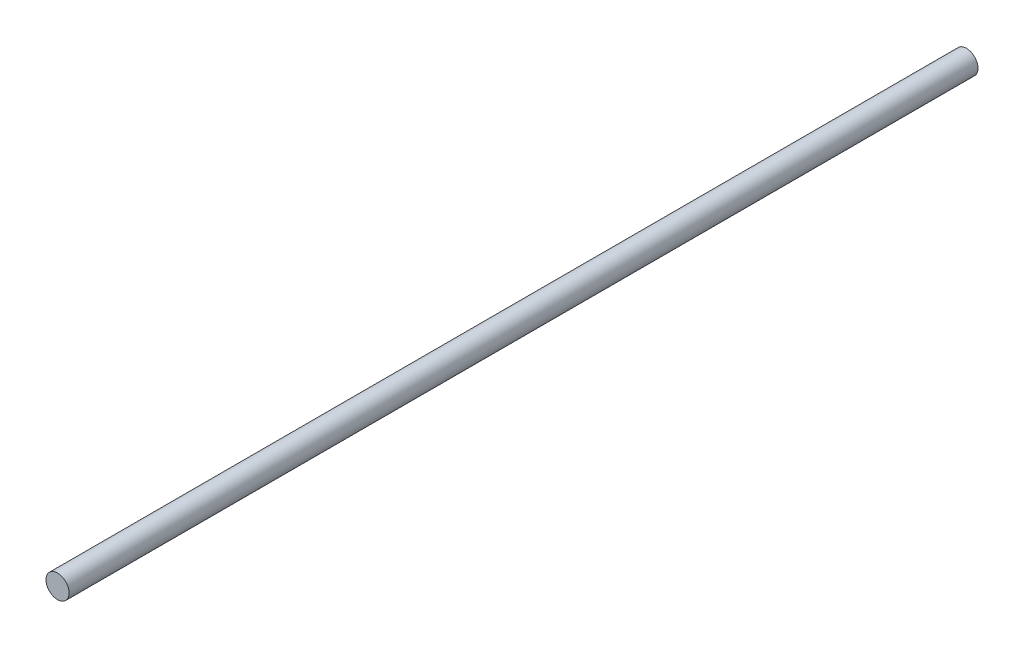
from build123d import *

# Parameters (mm, degrees)
SKETCH2_R           = 1.5
BOSS_EXTRUDE1_DEPTH = 118


with BuildPart() as part:
    # Sketch2 → Boss-Extrude1 (new body)
    with BuildSketch(Plane.XY):
        Circle(SKETCH2_R)
    extrude(amount=BOSS_EXTRUDE1_DEPTH)


solid = part.part
